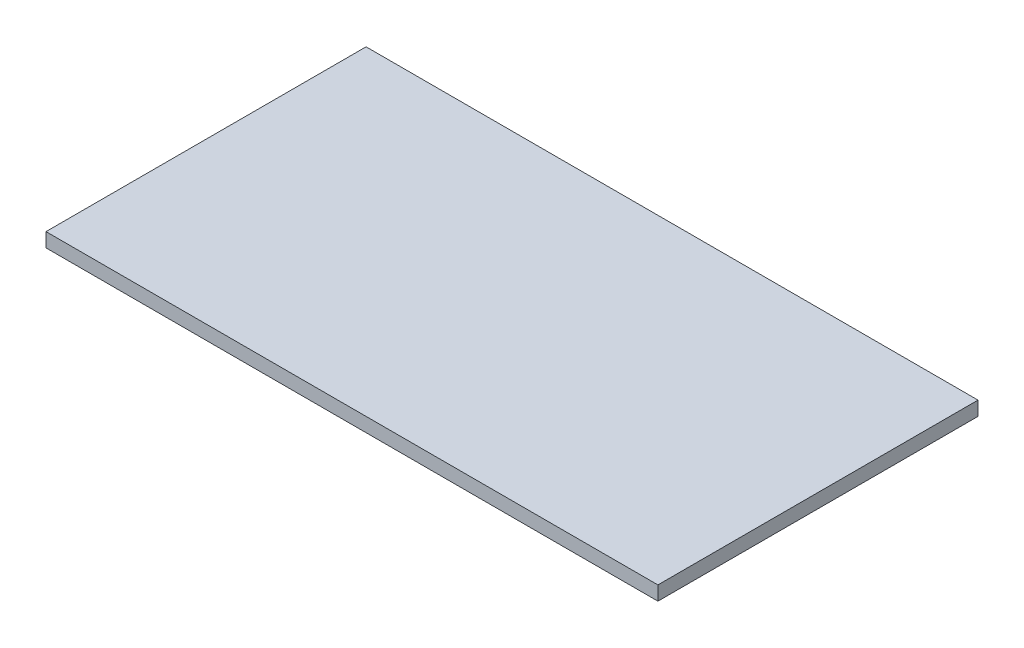
from build123d import *

# Parameters (mm, degrees)
SKETCH1_W           = 130
SKETCH1_H           = 68
BOSS_EXTRUDE1_DEPTH = 3


with BuildPart() as part:
    # Sketch1 → Boss-Extrude1 (new body)
    with BuildSketch(Plane(origin=(0, 0, 0), x_dir=(1, 0, 0), z_dir=(0, 1, 0))):
        with Locations((48.613202363, 15.377252912)):
            Rectangle(SKETCH1_W, SKETCH1_H)
    extrude(amount=BOSS_EXTRUDE1_DEPTH)


solid = part.part
